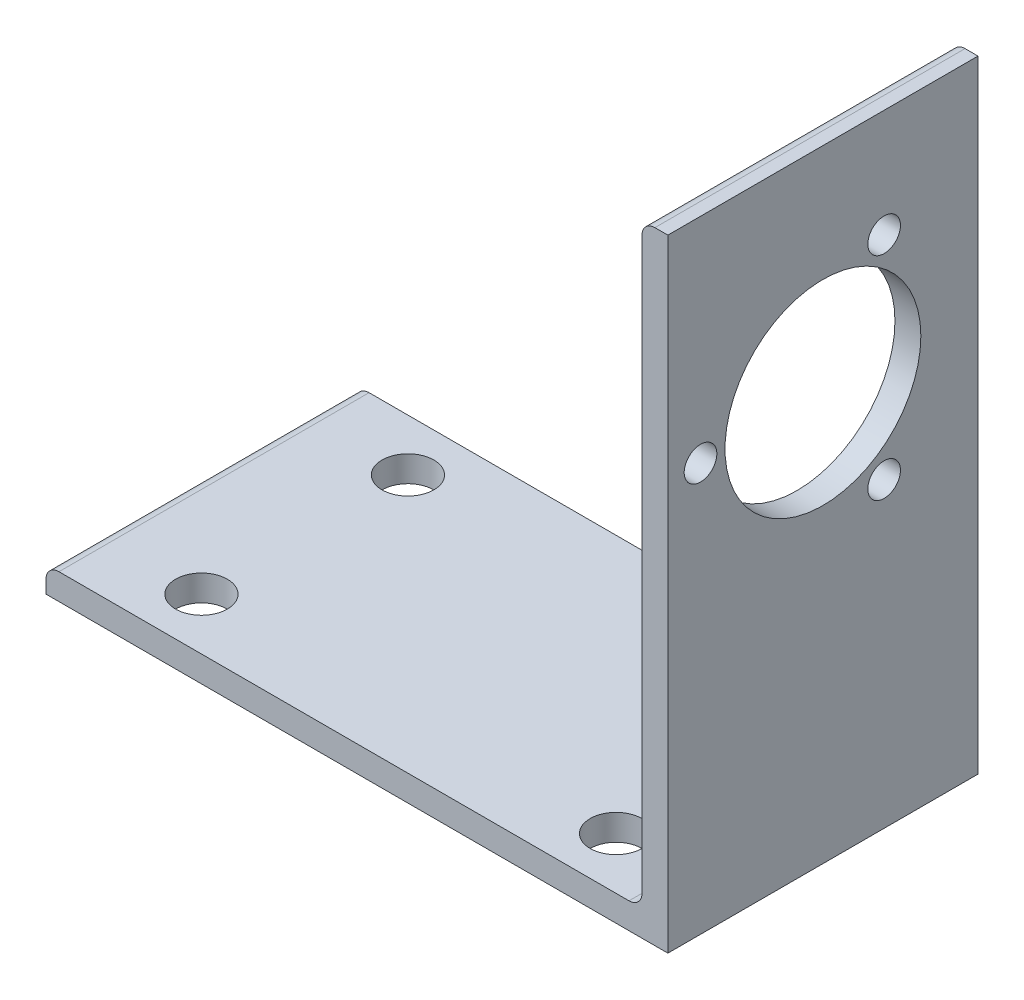
from build123d import *

# Parameters (mm, degrees)
BOSS_EXTRUDE1_DEPTH = 19
CUT_EXTRUDE1_REACH  = 40.1
SKETCH3_R           = 5.99948
CUT_EXTRUDE2_REACH  = 40.1
TOP_VIEW_R          = 1.5875


with BuildPart() as part:
    # Sketch2 → Boss-Extrude1 (new body)
    with BuildSketch(Plane.XY):
        with BuildLine():
            Line((-19.05, 0), (19.05, 0))
            Line((19.05, 0), (19.05, 38.1))
            Line((19.05, 38.1), (18.25625, 38.1))
            ThreePointArc((18.25625, 38.1), (17.694983992, 37.867516008), (17.4625, 37.30625))
            Line((17.4625, 37.30625), (17.4625, 2.38125))
            ThreePointArc((17.4625, 2.38125), (17.230016008, 1.819983992), (16.66875, 1.5875))
            Line((16.66875, 1.5875), (-18.25625, 1.5875))
            ThreePointArc((-18.25625, 1.5875), (-18.817516008, 1.355016008), (-19.05, 0.79375))
            Line((-19.05, 0.79375), (-19.05, 0))
        make_face()
    extrude(amount=-BOSS_EXTRUDE1_DEPTH)

    # Sketch3 → Cut-Extrude1 (cut, up to next)
    with BuildSketch(Plane(origin=(19.05, 0, 0), x_dir=(0, 0, -1), z_dir=(1, 0, 0)), mode=Mode.PRIVATE) as cut_extrude1_sk1:
        with Locations((9.5, 25)):
            Circle(SKETCH3_R)
    cut_extrude1_tool1 = extrude(cut_extrude1_sk1.sketch, amount=-CUT_EXTRUDE1_REACH, mode=Mode.PRIVATE) & part.part
    add(cut_extrude1_tool1.solids().sort_by_distance((19.05, 25, -9.5))[0], mode=Mode.SUBTRACT)
    # Sketch3 → Cut-Extrude1 (cut, up to next)
    with BuildSketch(Plane(origin=(19.05, 0, 0), x_dir=(0, 0, -1), z_dir=(1, 0, 0)), mode=Mode.PRIVATE) as cut_extrude1_sk2:
        with BuildLine():
            ThreePointArc((12.75, 30.629165125), (12.383974596, 31.995190528), (13.75, 32.361215932))
            ThreePointArc((13.75, 32.361215932), (14.116025404, 30.995190528), (12.75, 30.629165125))
        make_face()
    cut_extrude1_tool2 = extrude(cut_extrude1_sk2.sketch, amount=-CUT_EXTRUDE1_REACH, mode=Mode.PRIVATE) & part.part
    add(cut_extrude1_tool2.solids().sort_by_distance((19.05, 31.495191, -13.25))[0], mode=Mode.SUBTRACT)
    # Sketch3 → Cut-Extrude1 (cut, up to next)
    with BuildSketch(Plane(origin=(19.05, 0, 0), x_dir=(0, 0, -1), z_dir=(1, 0, 0)), mode=Mode.PRIVATE) as cut_extrude1_sk3:
        with BuildLine():
            ThreePointArc((12.75, 19.370834875), (14.116025404, 19.004809472), (13.75, 17.638784068))
            ThreePointArc((13.75, 17.638784068), (12.383974596, 18.004809472), (12.75, 19.370834875))
        make_face()
    cut_extrude1_tool3 = extrude(cut_extrude1_sk3.sketch, amount=-CUT_EXTRUDE1_REACH, mode=Mode.PRIVATE) & part.part
    add(cut_extrude1_tool3.solids().sort_by_distance((19.05, 18.504809, -13.25))[0], mode=Mode.SUBTRACT)
    # Sketch3 → Cut-Extrude1 (cut, up to next)
    with BuildSketch(Plane(origin=(19.05, 0, 0), x_dir=(0, 0, -1), z_dir=(1, 0, 0)), mode=Mode.PRIVATE) as cut_extrude1_sk4:
        with BuildLine():
            ThreePointArc((1, 25), (2, 26), (3, 25))
            ThreePointArc((3, 25), (2, 24), (1, 25))
        make_face()
    cut_extrude1_tool4 = extrude(cut_extrude1_sk4.sketch, amount=-CUT_EXTRUDE1_REACH, mode=Mode.PRIVATE) & part.part
    add(cut_extrude1_tool4.solids().sort_by_distance((19.05, 25, -2))[0], mode=Mode.SUBTRACT)

    # Top View → Cut-Extrude2 (cut, up to next)
    with BuildSketch(Plane.XZ, mode=Mode.PRIVATE) as cut_extrude2_sk1:
        with Locations((-12.7, -15.825)):
            Circle(TOP_VIEW_R)
    cut_extrude2_tool1 = extrude(cut_extrude2_sk1.sketch, amount=-CUT_EXTRUDE2_REACH, mode=Mode.PRIVATE) & part.part
    add(cut_extrude2_tool1.solids().sort_by_distance((-12.7, 0, -15.825))[0], mode=Mode.SUBTRACT)
    # Top View → Cut-Extrude2 (cut, up to next)
    with BuildSketch(Plane.XZ, mode=Mode.PRIVATE) as cut_extrude2_sk2:
        with Locations((12.7, -15.825)):
            Circle(TOP_VIEW_R)
    cut_extrude2_tool2 = extrude(cut_extrude2_sk2.sketch, amount=-CUT_EXTRUDE2_REACH, mode=Mode.PRIVATE) & part.part
    add(cut_extrude2_tool2.solids().sort_by_distance((12.7, 0, -15.825))[0], mode=Mode.SUBTRACT)
    # Top View → Cut-Extrude2 (cut, up to next)
    with BuildSketch(Plane.XZ, mode=Mode.PRIVATE) as cut_extrude2_sk3:
        with Locations((12.7, -3.175)):
            Circle(TOP_VIEW_R)
    cut_extrude2_tool3 = extrude(cut_extrude2_sk3.sketch, amount=-CUT_EXTRUDE2_REACH, mode=Mode.PRIVATE) & part.part
    add(cut_extrude2_tool3.solids().sort_by_distance((12.7, 0, -3.175))[0], mode=Mode.SUBTRACT)
    # Top View → Cut-Extrude2 (cut, up to next)
    with BuildSketch(Plane.XZ, mode=Mode.PRIVATE) as cut_extrude2_sk4:
        with Locations((-12.7, -3.175)):
            Circle(TOP_VIEW_R)
    cut_extrude2_tool4 = extrude(cut_extrude2_sk4.sketch, amount=-CUT_EXTRUDE2_REACH, mode=Mode.PRIVATE) & part.part
    add(cut_extrude2_tool4.solids().sort_by_distance((-12.7, 0, -3.175))[0], mode=Mode.SUBTRACT)


solid = part.part
